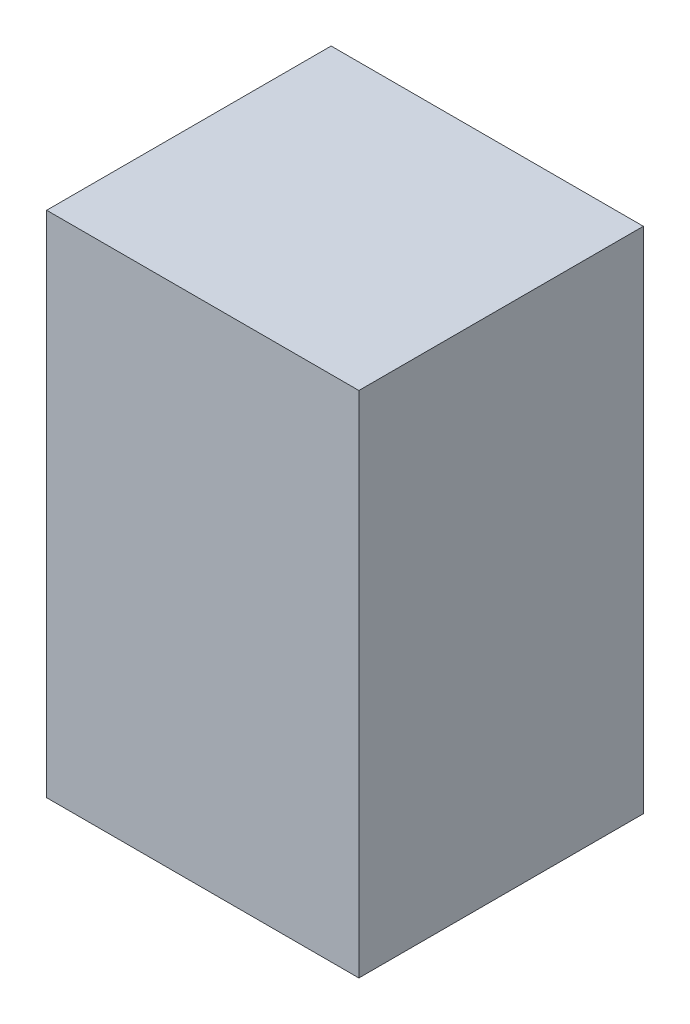
from build123d import *

# Parameters (mm, degrees)
SKETCH_1_W      = 270
SKETCH_1_H      = 440
EXTRUDE_1_DEPTH = 246


with BuildPart() as part:
    # 草图1 → 拉伸1 (new body)
    with BuildSketch(Plane.XY):
        Rectangle(SKETCH_1_W, SKETCH_1_H)
    extrude(amount=EXTRUDE_1_DEPTH)


solid = part.part
